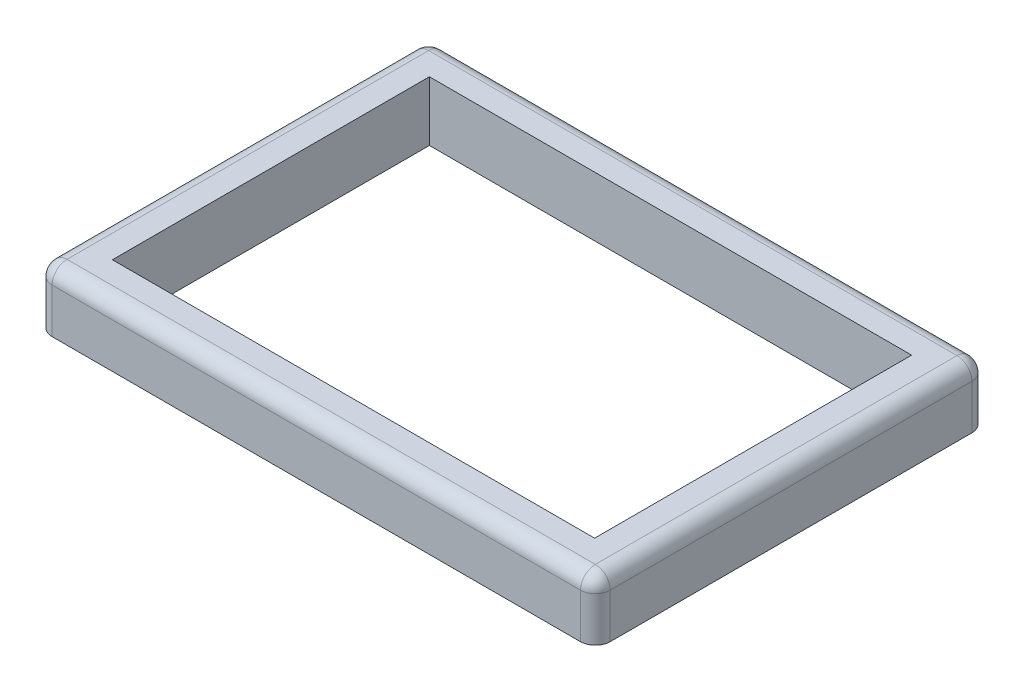
from build123d import *

# Parameters (mm, degrees)
SKETCH2_W           = 95.25
SKETCH2_H           = 66.802
SKETCH2_W_2         = 82.296
SKETCH2_H_2         = 54.102
BOSS_EXTRUDE1_DEPTH = 10.16
SKETCH3_R           = 1.9939
SKETCH3_R_2         = 1.8669
CUT_EXTRUDE1_DEPTH  = 7.62
SKETCH4_W           = 6.35
SKETCH4_H           = 6.2484
CUT_EXTRUDE2_DEPTH  = 2.54
SKETCH6_W           = 7.62
SKETCH6_H           = 6.2484
SKETCH6_W_2         = 6.35
CUT_EXTRUDE3_DEPTH  = 2.54
FILLET1_R           = 2.54


with BuildPart() as part:
    # Sketch2 → Boss-Extrude1 (new body)
    with BuildSketch(Plane(origin=(0, 0, 0), x_dir=(1, 0, 0), z_dir=(0, 1, 0))):
        Rectangle(SKETCH2_W, SKETCH2_H)
        Rectangle(SKETCH2_W_2, SKETCH2_H_2, mode=Mode.SUBTRACT)
    extrude(amount=BOSS_EXTRUDE1_DEPTH)

    # Sketch3 → Cut-Extrude1 (cut)
    with BuildSketch(Plane.XZ):
        with Locations((-44.45, 30.48)):
            Circle(SKETCH3_R)
        with Locations((44.45, 30.48)):
            Circle(SKETCH3_R)
        with Locations((44.45, -30.48)):
            Circle(SKETCH3_R_2)
        with Locations((-44.45, -30.48)):
            Circle(SKETCH3_R)
    extrude(amount=-CUT_EXTRUDE1_DEPTH, mode=Mode.SUBTRACT)

    # Sketch4 → Cut-Extrude2 (cut)
    with BuildSketch(Plane(origin=(0, 0, 27.051), x_dir=(-1, 0, 0), z_dir=(0, 0, -1))):
        with Locations((27.178, 3.1242)):
            Rectangle(SKETCH4_W, SKETCH4_H)
        with Locations((-27.178, 3.1242)):
            Rectangle(SKETCH4_W, SKETCH4_H)
    extrude(amount=-CUT_EXTRUDE2_DEPTH, mode=Mode.SUBTRACT)

    # Sketch6 → Cut-Extrude3 (cut)
    with BuildSketch(Plane.ZY.offset(-41.148)):
        with Locations((-23.241, 3.1242)):
            Rectangle(SKETCH6_W, SKETCH6_H)
        with Locations((23.241, 3.1242)):
            Rectangle(SKETCH6_W, SKETCH6_H)
        with Locations((0, 3.1242)):
            Rectangle(SKETCH6_W_2, SKETCH6_H)
    extrude(amount=-CUT_EXTRUDE3_DEPTH, mode=Mode.SUBTRACT)

    # Fillet1
    fillet1_edges = [part.edges().sort_by_distance(p)[0] for p in [
        (47.625, 10.16, 0),
        (0, 10.16, -33.401),
        (-47.625, 10.16, 0),
        (-47.625, 5.08, -33.401),
        (47.625, 5.08, -33.401),
        (47.625, 5.08, 33.401),
        (-47.625, 5.08, 33.401),
        (0, 10.16, 33.401),
    ]]
    fillet(fillet1_edges, radius=FILLET1_R)


solid = part.part
